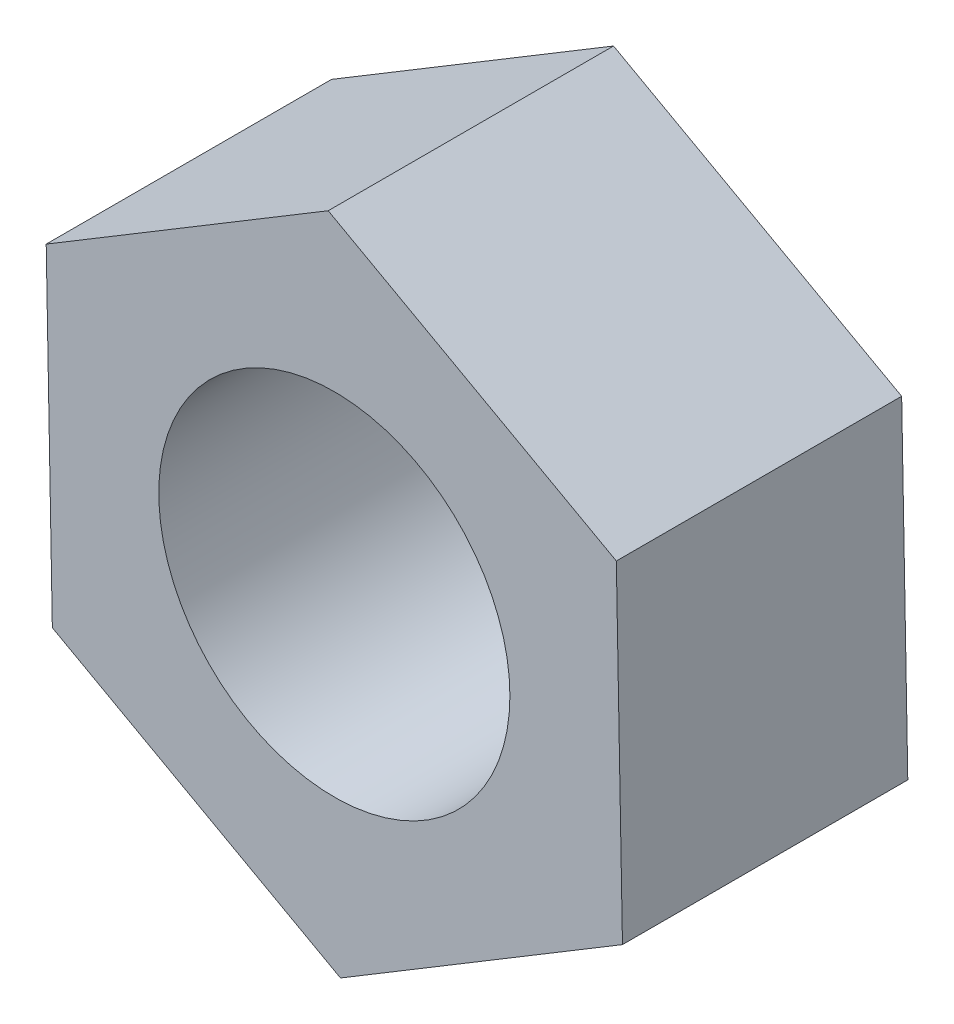
from build123d import *

# Parameters (mm, degrees)
SKETCH1_R           = 4
BOSS_EXTRUDE1_DEPTH = 6.5


with BuildPart() as part:
    # Sketch1 → Boss-Extrude1 (new body)
    with BuildSketch(Plane.XY):
        Polygon((-6.56400294, 3.628204157), (-6.42411844, -3.870491218), (0.1398845, -7.498695375), (6.56400294, -3.628204157), (6.42411844, 3.870491218), (-0.1398845, 7.498695375), align=None)
        Circle(SKETCH1_R, mode=Mode.SUBTRACT)
    extrude(amount=BOSS_EXTRUDE1_DEPTH)


solid = part.part
